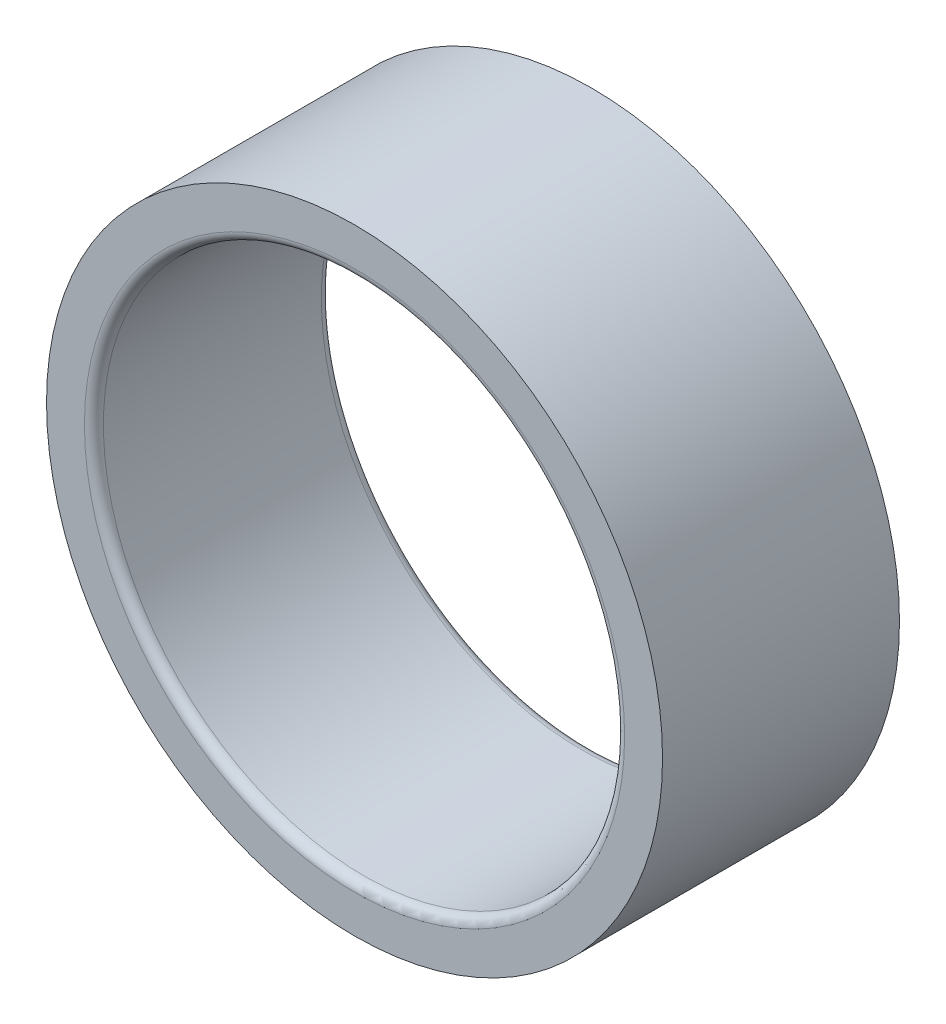
from build123d import *

# Parameters (mm, degrees)
SKETCH1_R      = 65
EXTRUDE1_DEPTH = 50
SKETCH2_R      = 55
EXTRUDE2_DEPTH = 51
FILLET1_R      = 2


with BuildPart() as part:
    # Sketch1 → Extrude1 (new body)
    with BuildSketch(Plane.XY):
        Circle(SKETCH1_R)
    extrude(amount=EXTRUDE1_DEPTH)

    # Sketch2 → Extrude2 (cut, through all)
    with BuildSketch(Plane.XY.offset(50)):
        Circle(SKETCH2_R)
    extrude(amount=-EXTRUDE2_DEPTH, mode=Mode.SUBTRACT)

    # Fillet1
    fillet1_edges = [part.edges().sort_by_distance(p)[0] for p in [
        (-55, 0, 0),
        (-55, 0, 50),
    ]]
    fillet(fillet1_edges, radius=FILLET1_R)


solid = part.part
